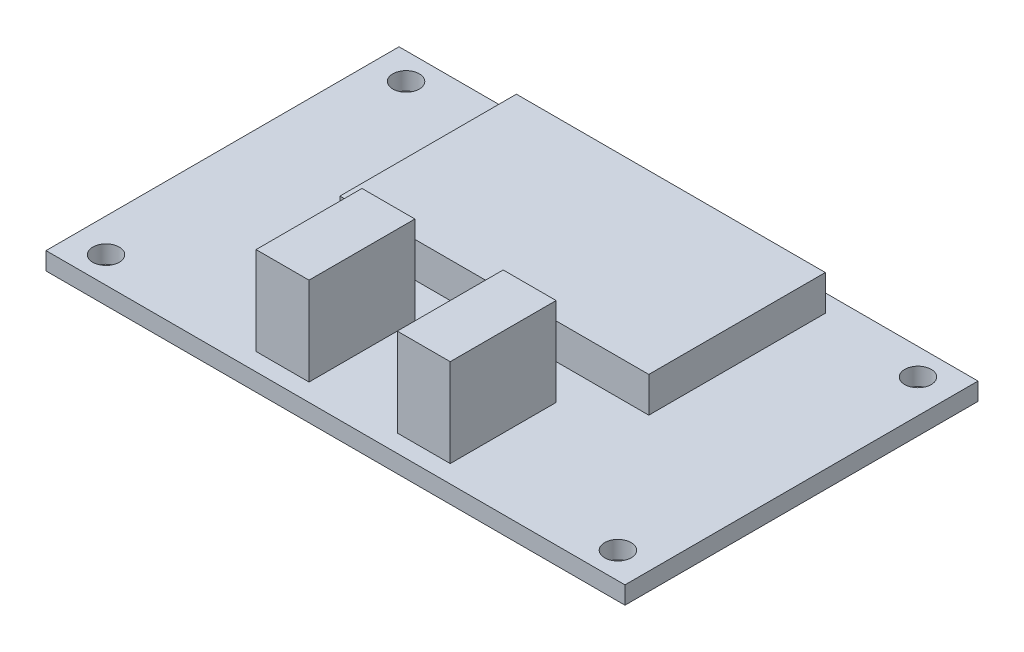
from build123d import *

# Parameters (mm, degrees)
SKETCH1_W           = 65.6
SKETCH1_H           = 40
BOSS_EXTRUDE1_DEPTH = 2
SKETCH2_R           = 1.5
CUT_EXTRUDE1_DEPTH  = 3
SKETCH3_W           = 35
SKETCH3_H           = 20
BOSS_EXTRUDE2_DEPTH = 4
SKETCH4_W           = 6
SKETCH4_H           = 12
BOSS_EXTRUDE3_DEPTH = 10


with BuildPart() as part:
    # Sketch1 → Boss-Extrude1 (new body)
    with BuildSketch(Plane(origin=(0, 0, 0), x_dir=(1, 0, 0), z_dir=(0, 1, 0))):
        Rectangle(SKETCH1_W, SKETCH1_H)
    extrude(amount=BOSS_EXTRUDE1_DEPTH)

    # Sketch2 → Cut-Extrude1 (cut, through all)
    with BuildSketch(Plane(origin=(0, 2, 0), x_dir=(1, 0, 0), z_dir=(0, 1, 0))):
        with Locations((-29, 17)):
            Circle(SKETCH2_R)
        with Locations((29, 17)):
            Circle(SKETCH2_R)
        with Locations((29, -17)):
            Circle(SKETCH2_R)
        with Locations((-29, -17)):
            Circle(SKETCH2_R)
    extrude(amount=-CUT_EXTRUDE1_DEPTH, mode=Mode.SUBTRACT)

    # Sketch3 → Boss-Extrude2 (add)
    with BuildSketch(Plane(origin=(0, 2, 0), x_dir=(1, 0, 0), z_dir=(0, 1, 0))):
        with Locations((0, 8)):
            Rectangle(SKETCH3_W, SKETCH3_H)
    extrude(amount=BOSS_EXTRUDE2_DEPTH)

    # Sketch4 → Boss-Extrude3 (add)
    with BuildSketch(Plane(origin=(0, 2, 0), x_dir=(1, 0, 0), z_dir=(0, 1, 0))):
        with Locations((-8, -12)):
            Rectangle(SKETCH4_W, SKETCH4_H)
        with Locations((8, -12)):
            Rectangle(SKETCH4_W, SKETCH4_H)
    extrude(amount=BOSS_EXTRUDE3_DEPTH)


solid = part.part
